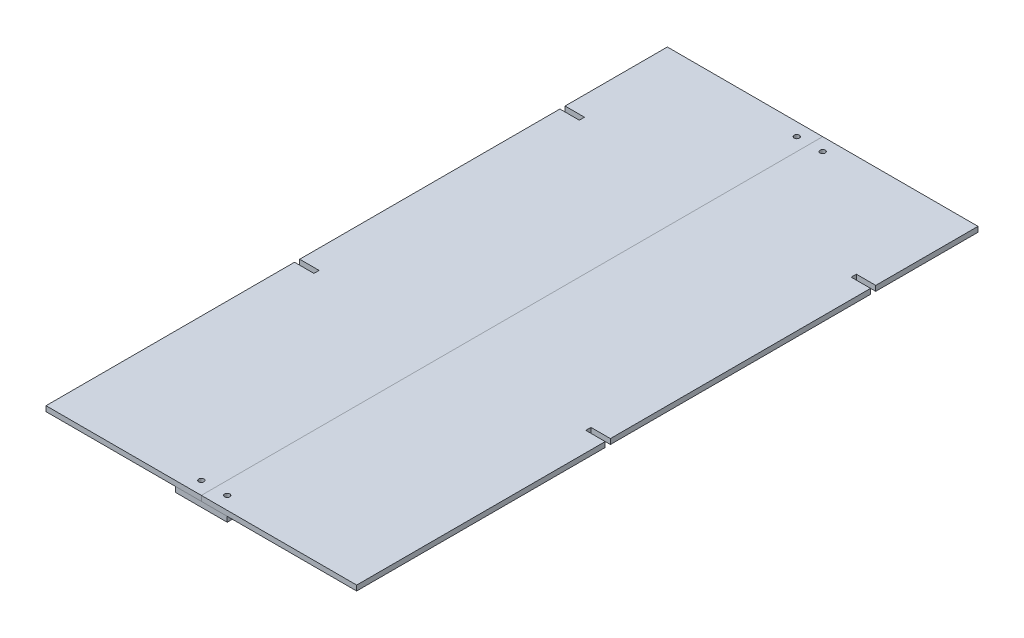
from build123d import *

# Parameters (mm, degrees)
SKETCH1_W                       = 304.8
SKETCH1_H                       = 609.6
BOSS_EXTRUDE1_DEPTH             = 5.08
SKETCH2_W                       = 19.05
SKETCH2_H                       = 5.08
CUT_EXTRUDE1_DEPTH              = 6.08
SKETCH6_W                       = 2.5527
SKETCH6_H                       = 5.08
F_10_CLEARANCE_HOLE1_AT_2_COUNT = 2
F_10_CLEARANCE_HOLE1_AT_2_PITCH = 584.751913208
F_10_CLEARANCE_HOLE1_AT_3_COUNT = 2
F_10_CLEARANCE_HOLE1_AT_3_PITCH = 25.4
F_10_CLEARANCE_HOLE1_AT_4_COUNT = 2
F_10_CLEARANCE_HOLE1_AT_4_PITCH = 584.2
SKETCH7_W                       = 50.8
SKETCH7_H                       = 609.6
BOSS_EXTRUDE2_DEPTH             = 5.08
SKETCH9_W                       = 2.0193
SKETCH9_H                       = 5.08
F_10_32_TAPPED_HOLE1_AT_2_COUNT = 2
F_10_32_TAPPED_HOLE1_AT_2_PITCH = 25.4
F_10_32_TAPPED_HOLE1_AT_3_COUNT = 2
F_10_32_TAPPED_HOLE1_AT_3_PITCH = 584.2
F_10_32_TAPPED_HOLE1_AT_4_COUNT = 2
F_10_32_TAPPED_HOLE1_AT_4_PITCH = 584.751913208


with BuildPart() as part:
    # Sketch1 → Boss-Extrude1 (new body)
    with BuildSketch(Plane(origin=(0, 0, 0), x_dir=(1, 0, 0), z_dir=(0, 1, 0))):
        Rectangle(SKETCH1_W, SKETCH1_H)
    extrude(amount=BOSS_EXTRUDE1_DEPTH)

    # Sketch2 → Cut-Extrude1 (cut, through all)
    with BuildSketch(Plane(origin=(0, 5.08, 0), x_dir=(1, 0, 0), z_dir=(0, 1, 0))):
        with Locations((142.875, -58.42)):
            Rectangle(SKETCH2_W, SKETCH2_H)
        with Locations((142.875, 201.93)):
            Rectangle(SKETCH2_W, SKETCH2_H)
        with Locations((-142.875, 201.93)):
            Rectangle(SKETCH2_W, SKETCH2_H)
        with Locations((-142.875, -58.42)):
            Rectangle(SKETCH2_W, SKETCH2_H)
    extrude(amount=-CUT_EXTRUDE1_DEPTH, mode=Mode.SUBTRACT)


with BuildPart() as body_2:
    # Split1: the piece on the far side of the plane
    add(part.part)
    split(bisect_by=Plane(origin=(0, 0, 0), x_dir=(0, 0, 1), z_dir=(1, 0, 0)), keep=Keep.BOTTOM)

    # Sketch6 → #10 Clearance Hole1 (revolve, cut)
    with BuildSketch(Plane(origin=(-12.7, 5.08, -292.1), x_dir=(0, 0, 1), z_dir=(1, 0, 0))):
        with Locations((1.27635, 2.54)):
            Rectangle(SKETCH6_W, SKETCH6_H)
    f_10_clearance_hole1 = revolve(axis=Axis((-12.7, 11.43, -292.1), (0, -1, 0)), mode=Mode.SUBTRACT)

    # #10 Clearance Hole1 at 4: #10 Clearance Hole1 ×2
    with Locations(*[(0, 0, i * F_10_CLEARANCE_HOLE1_AT_4_PITCH) for i in range(1, F_10_CLEARANCE_HOLE1_AT_4_COUNT)]):
        add(f_10_clearance_hole1, mode=Mode.SUBTRACT)


with BuildPart() as part_1:
    add(part.part)

    # Split1
    split(bisect_by=Plane(origin=(0, 0, 0), x_dir=(0, 0, 1), z_dir=(1, 0, 0)), keep=Keep.TOP)

    # #10 Clearance Hole1 at 2: #10 Clearance Hole1 ×2
    with Locations(*[Vector(0.043437224, 0, 0.999056158) * (i * F_10_CLEARANCE_HOLE1_AT_2_PITCH) for i in range(1, F_10_CLEARANCE_HOLE1_AT_2_COUNT)]):
        add(f_10_clearance_hole1, mode=Mode.SUBTRACT)

    # #10 Clearance Hole1 at 3: #10 Clearance Hole1 ×2
    with Locations(*[(i * F_10_CLEARANCE_HOLE1_AT_3_PITCH, 0, 0) for i in range(1, F_10_CLEARANCE_HOLE1_AT_3_COUNT)]):
        add(f_10_clearance_hole1, mode=Mode.SUBTRACT)


with BuildPart() as body_3:
    # Sketch7 → Boss-Extrude2 (new body)
    with BuildSketch(Plane.XZ):
        Rectangle(SKETCH7_W, SKETCH7_H)
    extrude(amount=BOSS_EXTRUDE2_DEPTH)

    # Sketch9 → #10-32 Tapped Hole1 (revolve, cut)
    with BuildSketch(Plane(origin=(-12.7, 0, 292.1), x_dir=(0, 0, 1), z_dir=(1, 0, 0))):
        with Locations((1.00965, 2.54)):
            Rectangle(SKETCH9_W, SKETCH9_H)
    f_10_32_tapped_hole1 = revolve(axis=Axis((-12.7, 6.35, 292.1), (0, -1, 0)), mode=Mode.SUBTRACT)

    # #10-32 Tapped Hole1 at 2: #10-32 Tapped Hole1 ×2
    with Locations(*[(i * F_10_32_TAPPED_HOLE1_AT_2_PITCH, 0, 0) for i in range(1, F_10_32_TAPPED_HOLE1_AT_2_COUNT)]):
        add(f_10_32_tapped_hole1, mode=Mode.SUBTRACT)

    # #10-32 Tapped Hole1 at 3: #10-32 Tapped Hole1 ×2
    with Locations(*[(0, 0, -i * F_10_32_TAPPED_HOLE1_AT_3_PITCH) for i in range(1, F_10_32_TAPPED_HOLE1_AT_3_COUNT)]):
        add(f_10_32_tapped_hole1, mode=Mode.SUBTRACT)

    # #10-32 Tapped Hole1 at 4: #10-32 Tapped Hole1 ×2
    with Locations(*[Vector(0.043437224, 0, -0.999056158) * (i * F_10_32_TAPPED_HOLE1_AT_4_PITCH) for i in range(1, F_10_32_TAPPED_HOLE1_AT_4_COUNT)]):
        add(f_10_32_tapped_hole1, mode=Mode.SUBTRACT)


solid = Compound([body_2.part, part_1.part, body_3.part])
